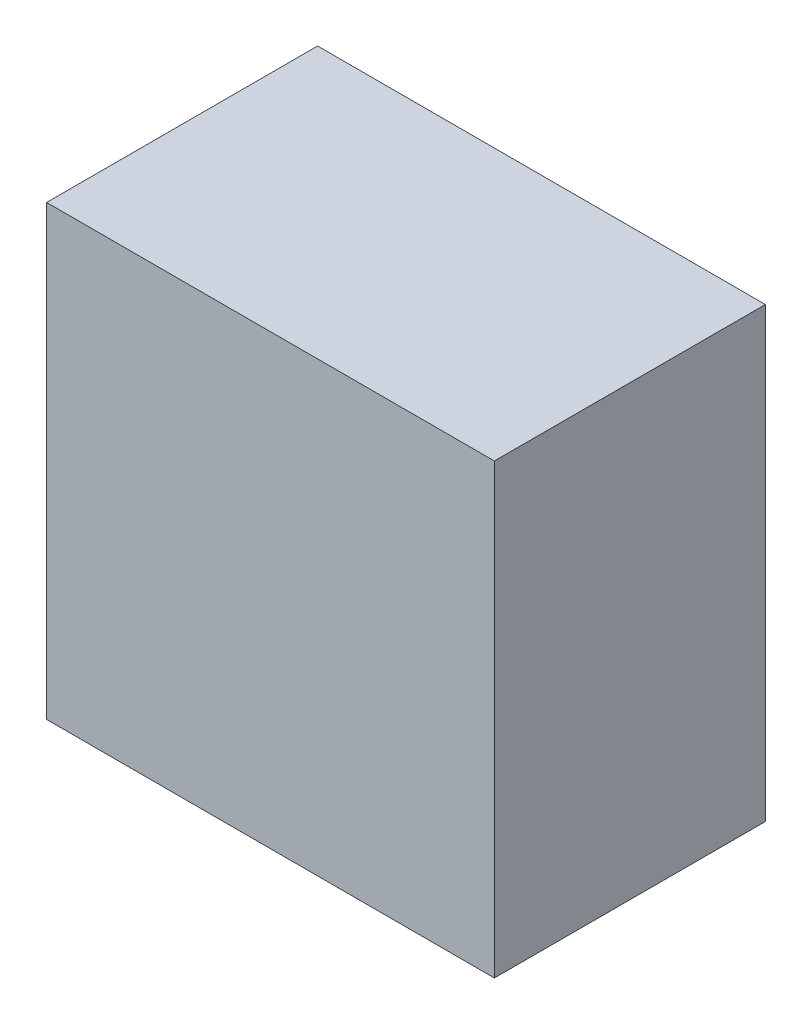
from build123d import *

# Parameters (mm, degrees)
ESQUISSE1_W        = 380
ESQUISSE1_H        = 380
ESQUISSE1_W_2      = 340
ESQUISSE1_H_2      = 340
BOSS_EXTRU_1_DEPTH = 210
ESQUISSE2_W        = 380
ESQUISSE2_H        = 380
BOSS_EXTRU_2_DEPTH = 20


with BuildPart() as part:
    # Esquisse1 → Boss.-Extru.1 (new body)
    with BuildSketch(Plane.XY):
        Rectangle(ESQUISSE1_W, ESQUISSE1_H)
        Rectangle(ESQUISSE1_W_2, ESQUISSE1_H_2, mode=Mode.SUBTRACT)
    extrude(amount=BOSS_EXTRU_1_DEPTH)

    # Esquisse2 → Boss.-Extru.2 (add)
    with BuildSketch(Plane.XY.offset(210)):
        Rectangle(ESQUISSE2_W, ESQUISSE2_H)
    extrude(amount=BOSS_EXTRU_2_DEPTH)


solid = part.part
